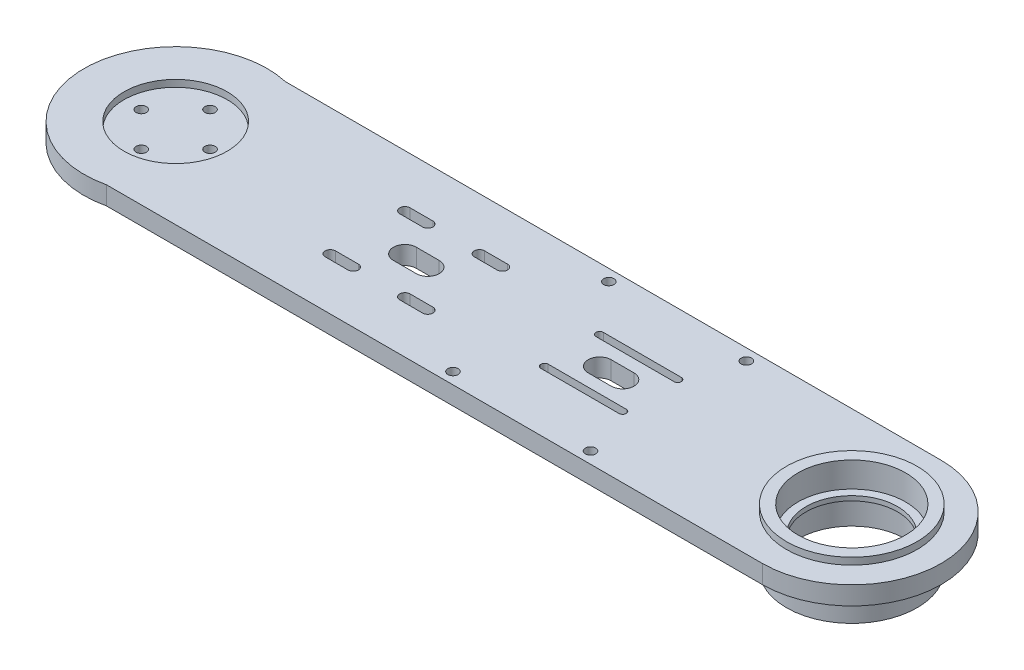
from build123d import *

# Parameters (mm, degrees)
SKETCH4_R                = 22.5
SKETCH4_R_2              = 2.25
BOSS_EXTRUDE3_DEPTH      = 5
SKETCH4_4_R              = 28.5
SKETCH4_4_R_2            = 22.5
BOSS_EXTRUDE4_DEPTH      = 8
BOSS_EXTRUDE5_DEPTH      = 11
BOSS_EXTRUDE5_DEPTH_BACK = 14
SKETCH4_5_R              = 28.5
SKETCH4_5_R_2            = 23.5
SKETCH4_6_R              = 23.5
SKETCH4_6_R_2            = 20
BOSS_EXTRUDE6_DEPTH      = 2
SKETCH5_R                = 2.25
CUT_EXTRUDE1_DEPTH       = 10


with BuildPart() as part:
    # Sketch4 → Boss-Extrude3 (new body)
    with BuildSketch(Plane(origin=(0, 0, 0), x_dir=(1, 0, 0), z_dir=(0, 1, 0))):
        Circle(SKETCH4_R)
        with Locations((0, -15)):
            Circle(SKETCH4_R_2, mode=Mode.SUBTRACT)
        with Locations((15, 0)):
            Circle(SKETCH4_R_2, mode=Mode.SUBTRACT)
        with Locations((-15, 0)):
            Circle(SKETCH4_R_2, mode=Mode.SUBTRACT)
        with Locations((0, 15)):
            Circle(SKETCH4_R_2, mode=Mode.SUBTRACT)
    extrude(amount=BOSS_EXTRUDE3_DEPTH)

    # Sketch4_4 → Boss-Extrude4 (add)
    with BuildSketch(Plane(origin=(0, 0, 0), x_dir=(1, 0, 0), z_dir=(0, 1, 0))):
        with BuildLine():
            ThreePointArc((8.888194417, 39), (-40, 0), (8.888194417, -39))
            Line((8.888194417, -39), (295, -39))
            ThreePointArc((295, -39), (334, 0), (295, 39))
            Line((295, 39), (8.888194417, 39))
        make_face()
        with BuildLine():
            Line((93.736544033, -18.513455967), (83.736544033, -18.513455967))
            ThreePointArc((83.736544033, -18.513455967), (81.486544033, -16.263455967), (83.736544033, -14.013455967))
            Line((83.736544033, -14.013455967), (93.736544033, -14.013455967))
            ThreePointArc((93.736544033, -14.013455967), (95.986544033, -16.263455967), (93.736544033, -18.513455967))
        make_face(mode=Mode.SUBTRACT)
        with BuildLine():
            Line((126.263455967, -18.513455967), (116.263455967, -18.513455967))
            ThreePointArc((116.263455967, -18.513455967), (114.013455967, -16.263455967), (116.263455967, -14.013455967))
            Line((116.263455967, -14.013455967), (126.263455967, -14.013455967))
            ThreePointArc((126.263455967, -14.013455967), (128.513455967, -16.263455967), (126.263455967, -18.513455967))
        make_face(mode=Mode.SUBTRACT)
        with BuildLine():
            Line((172.97918472, -10.42081528), (207.02081528, -10.42081528))
            ThreePointArc((207.02081528, -10.42081528), (208.62081528, -12.02081528), (207.02081528, -13.62081528))
            Line((207.02081528, -13.62081528), (172.97918472, -13.62081528))
            ThreePointArc((172.97918472, -13.62081528), (171.37918472, -12.02081528), (172.97918472, -10.42081528))
        make_face(mode=Mode.SUBTRACT)
        with BuildLine():
            ThreePointArc((100, -5), (95, 0), (100, 5))
            Line((100, 5), (110, 5))
            ThreePointArc((110, 5), (115, 0), (110, -5))
            Line((110, -5), (100, -5))
        make_face(mode=Mode.SUBTRACT)
        with BuildLine():
            ThreePointArc((83.736544033, 14.013455967), (81.486544033, 16.263455967), (83.736544033, 18.513455967))
            Line((83.736544033, 18.513455967), (93.736544033, 18.513455967))
            ThreePointArc((93.736544033, 18.513455967), (95.986544033, 16.263455967), (93.736544033, 14.013455967))
            Line((93.736544033, 14.013455967), (83.736544033, 14.013455967))
        make_face(mode=Mode.SUBTRACT)
        with BuildLine():
            ThreePointArc((116.263455967, 14.013455967), (114.013455967, 16.263455967), (116.263455967, 18.513455967))
            Line((116.263455967, 18.513455967), (126.263455967, 18.513455967))
            ThreePointArc((126.263455967, 18.513455967), (128.513455967, 16.263455967), (126.263455967, 14.013455967))
            Line((126.263455967, 14.013455967), (116.263455967, 14.013455967))
        make_face(mode=Mode.SUBTRACT)
        with BuildLine():
            ThreePointArc((195, 5), (200, 0), (195, -5))
            Line((195, -5), (185, -5))
            ThreePointArc((185, -5), (180, 0), (185, 5))
            Line((185, 5), (195, 5))
        make_face(mode=Mode.SUBTRACT)
        with BuildLine():
            ThreePointArc((207.02081528, 13.62081528), (208.62081528, 12.02081528), (207.02081528, 10.42081528))
            Line((207.02081528, 10.42081528), (172.97918472, 10.42081528))
            ThreePointArc((172.97918472, 10.42081528), (171.37918472, 12.02081528), (172.97918472, 13.62081528))
            Line((172.97918472, 13.62081528), (207.02081528, 13.62081528))
        make_face(mode=Mode.SUBTRACT)
        with Locations((295, 0)):
            Circle(SKETCH4_4_R, mode=Mode.SUBTRACT)
        Circle(SKETCH4_4_R_2, mode=Mode.SUBTRACT)
    extrude(amount=BOSS_EXTRUDE4_DEPTH)

    # Sketch4_5 → Boss-Extrude5 (add, two sides: drawn at the far end of the back side and taken through both)
    with BuildSketch(Plane(origin=(0, 0, 0), x_dir=(1, 0, 0), z_dir=(0, 1, 0)).offset(-BOSS_EXTRUDE5_DEPTH_BACK)):
        with Locations((295, 0)):
            Circle(SKETCH4_5_R)
        with Locations((295, 0)):
            Circle(SKETCH4_5_R_2, mode=Mode.SUBTRACT)
    extrude(amount=BOSS_EXTRUDE5_DEPTH + BOSS_EXTRUDE5_DEPTH_BACK)

    # Sketch4_6 → Boss-Extrude6 (add)
    with BuildSketch(Plane(origin=(0, 0, 0), x_dir=(1, 0, 0), z_dir=(0, 1, 0))):
        with Locations((295, 0)):
            Circle(SKETCH4_6_R)
        with Locations((295, 0)):
            Circle(SKETCH4_6_R_2, mode=Mode.SUBTRACT)
    extrude(amount=-BOSS_EXTRUDE6_DEPTH)

    # Sketch5 → Cut-Extrude1 (cut)
    with BuildSketch(Plane.XZ):
        with Locations((155, 34)):
            Circle(SKETCH5_R)
        with Locations((215, 34)):
            Circle(SKETCH5_R)
        with Locations((215, -34)):
            Circle(SKETCH5_R)
        with Locations((155, -34)):
            Circle(SKETCH5_R)
    extrude(amount=-CUT_EXTRUDE1_DEPTH, mode=Mode.SUBTRACT)


solid = part.part
